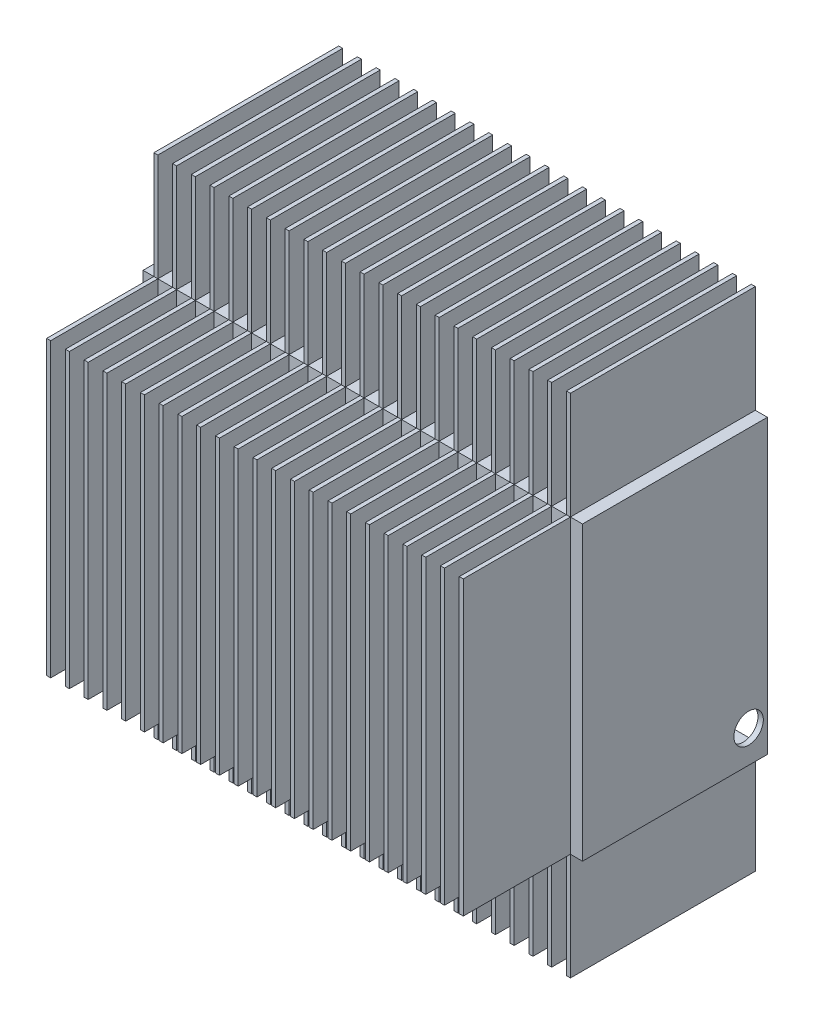
from build123d import *

# Parameters (mm, degrees)
SKETCH1_W            = 164
SKETCH1_H            = 109
BOSS_EXTRUDE1_DEPTH  = 69
SKETCH2_W            = 1.5
SKETCH2_H            = 109
BOSS_EXTRUDE3_DEPTH  = 40
LPATTERN3_COUNT      = 23
LPATTERN3_PITCH      = 7
SKETCH4_W            = 160
SKETCH4_H            = 105
CUT_EXTRUDE5_DEPTH   = 65
SKETCH6_W            = 1.5
SKETCH6_H            = 69
BOSS_EXTRUDE4_DEPTH  = 40
LPATTERN4_COUNT      = 23
LPATTERN4_PITCH      = 7
SKETCH7_W            = 1.5
SKETCH7_H            = 69
BOSS_EXTRUDE5_DEPTH  = 40
LPATTERN5_COUNT      = 23
LPATTERN5_PITCH      = 7
SKETCH19_W           = 37.94
SKETCH19_H           = 34
BOSS_EXTRUDE8_DEPTH  = 55
SKETCH20_W           = 12.95
SKETCH20_H           = 109
BOSS_EXTRUDE9_DEPTH  = 51
SKETCH26_W           = 15.88
SKETCH26_H           = 109
BOSS_EXTRUDE10_DEPTH = 58
SKETCH29_R           = 2
CUT_EXTRUDE12_DEPTH  = 2
SKETCH31_R           = 5.5
CUT_EXTRUDE13_DEPTH  = 2
SKETCH32_W           = 160
SKETCH32_H           = 105
CUT_EXTRUDE14_DEPTH  = 2


with BuildPart() as part:
    # Sketch1 → Boss-Extrude1 (new body)
    with BuildSketch(Plane.XY):
        with Locations((-82, 54.5)):
            Rectangle(SKETCH1_W, SKETCH1_H)
    extrude(amount=-BOSS_EXTRUDE1_DEPTH)

    # Sketch2 → Boss-Extrude3 (add)
    with BuildSketch(Plane.XY):
        with Locations((-159.25, 54.5)):
            Rectangle(SKETCH2_W, SKETCH2_H)
    boss_extrude3 = extrude(amount=BOSS_EXTRUDE3_DEPTH)

    # LPattern3: Boss-Extrude3 ×23
    with Locations(*[(i * LPATTERN3_PITCH, 0, 0) for i in range(1, LPATTERN3_COUNT)]):
        add(boss_extrude3)

    # Sketch4 → Cut-Extrude5 (cut)
    with BuildSketch(Plane.XY.offset(-67)):
        with Locations((-82, 54.5)):
            Rectangle(SKETCH4_W, SKETCH4_H)
    extrude(amount=CUT_EXTRUDE5_DEPTH, mode=Mode.SUBTRACT)

    # Sketch6 → Boss-Extrude4 (add)
    with BuildSketch(Plane(origin=(0, 0, 0), x_dir=(-1, 0, 0), z_dir=(0, -1, 0))):
        with Locations((5.25, 34.5)):
            Rectangle(SKETCH6_W, SKETCH6_H)
    boss_extrude4 = extrude(amount=BOSS_EXTRUDE4_DEPTH)

    # LPattern4: Boss-Extrude4 ×23
    with Locations(*[(-i * LPATTERN4_PITCH, 0, 0) for i in range(1, LPATTERN4_COUNT)]):
        add(boss_extrude4)

    # Sketch7 → Boss-Extrude5 (add)
    with BuildSketch(Plane(origin=(0, 109, 0), x_dir=(1, 0, 0), z_dir=(0, 1, 0))):
        with Locations((-159.25, 34.5)):
            Rectangle(SKETCH7_W, SKETCH7_H)
    boss_extrude5 = extrude(amount=BOSS_EXTRUDE5_DEPTH)

    # LPattern5: Boss-Extrude5 ×23
    with Locations(*[(i * LPATTERN5_PITCH, 0, 0) for i in range(1, LPATTERN5_COUNT)]):
        add(boss_extrude5)

    # Sketch19 → Boss-Extrude8 (add)
    with BuildSketch(Plane.XY.offset(-2)):
        with Locations((-145.03, 92)):
            Rectangle(SKETCH19_W, SKETCH19_H)
    extrude(amount=-BOSS_EXTRUDE8_DEPTH)

    # Sketch20 → Boss-Extrude9 (add)
    with BuildSketch(Plane.XY.offset(-2)):
        with Locations((-119.585, 54.5)):
            Rectangle(SKETCH20_W, SKETCH20_H)
    extrude(amount=-BOSS_EXTRUDE9_DEPTH)

    # Sketch26 → Boss-Extrude10 (add)
    with BuildSketch(Plane.XY.offset(-2)):
        with Locations((-47.06, 54.5)):
            Rectangle(SKETCH26_W, SKETCH26_H)
    extrude(amount=-BOSS_EXTRUDE10_DEPTH)

    # Sketch29 → Cut-Extrude12 (cut)
    with BuildSketch(Plane.ZY.offset(164)):
        with Locations((-58.00234212, 9.939563953)):
            Circle(SKETCH29_R)
        with Locations((-58.00234212, 14.939563953)):
            Circle(SKETCH29_R)
        with Locations((-58.00234212, 19.939563953)):
            Circle(SKETCH29_R)
        with Locations((-58.00234212, 27.939563953)):
            Circle(SKETCH29_R)
        with Locations((-58.00234212, 36.939563953)):
            Circle(SKETCH29_R)
        with Locations((-58.00234212, 46.939563953)):
            Circle(SKETCH29_R)
        with Locations((-58.00234212, 56.939563953)):
            Circle(SKETCH29_R)
        with Locations((-58.00234212, 66.939563953)):
            Circle(SKETCH29_R)
    extrude(amount=-CUT_EXTRUDE12_DEPTH, mode=Mode.SUBTRACT)

    # Sketch31 → Cut-Extrude13 (cut)
    with BuildSketch(Plane(origin=(0, 0, 0), x_dir=(0, 0, -1), z_dir=(1, 0, 0))):
        with Locations((62, 12)):
            Circle(SKETCH31_R)
    extrude(amount=-CUT_EXTRUDE13_DEPTH, mode=Mode.SUBTRACT)

    # Sketch32 → Cut-Extrude14 (cut)
    with BuildSketch(Plane(origin=(0, 0, -69), x_dir=(-1, 0, 0), z_dir=(0, 0, -1))):
        with Locations((82, 54.5)):
            Rectangle(SKETCH32_W, SKETCH32_H)
    extrude(amount=-CUT_EXTRUDE14_DEPTH, mode=Mode.SUBTRACT)


solid = part.part
